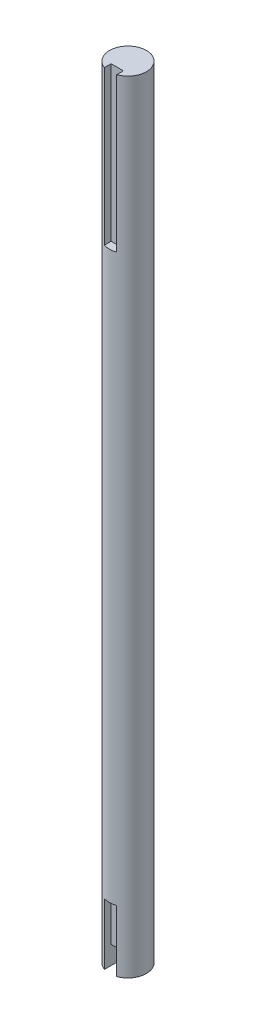
from build123d import *

# Parameters (mm, degrees)
SKETCH1_R               = 6
BOSS_EXTRUDE1_DEPTH     = 254
SKETCH2_W               = 4
SKETCH2_H               = 5
CUT_EXTRUDE3_DEPTH      = 20
CUT_EXTRUDE3_DEPTH_BACK = 0.0001
CUT_EXTRUDE4_START      = 254
SKETCH2_2_W             = 4
SKETCH2_2_H             = 5
CUT_EXTRUDE4_DEPTH      = 50
SKETCH3_W               = 4
SKETCH3_H               = 10
CUT_EXTRUDE6_DEPTH      = 6


with BuildPart() as part:
    # Sketch1 → Boss-Extrude1 (new body)
    with BuildSketch(Plane(origin=(0, 0, 0), x_dir=(1, 0, 0), z_dir=(0, 1, 0))):
        Circle(SKETCH1_R)
    extrude(amount=BOSS_EXTRUDE1_DEPTH)

    # Sketch2 → Cut-Extrude3 (cut, two sides)
    with BuildSketch(Plane(origin=(0, 0, 0), x_dir=(1, 0, 0), z_dir=(0, 1, 0))) as cut_extrude3_sk:
        with Locations((0, -6)):
            Rectangle(SKETCH2_W, SKETCH2_H)
    extrude(amount=CUT_EXTRUDE3_DEPTH, mode=Mode.SUBTRACT)
    extrude(cut_extrude3_sk.sketch, amount=-CUT_EXTRUDE3_DEPTH_BACK, mode=Mode.SUBTRACT)

    # Sketch2_2 → Cut-Extrude4 (cut)
    with BuildSketch(Plane(origin=(0, 0, 0), x_dir=(1, 0, 0), z_dir=(0, 1, 0)).offset(CUT_EXTRUDE4_START)):
        with Locations((0, -6)):
            Rectangle(SKETCH2_2_W, SKETCH2_2_H)
    extrude(amount=-CUT_EXTRUDE4_DEPTH, mode=Mode.SUBTRACT)

    # Sketch3 → Cut-Extrude6 (cut)
    with BuildSketch(Plane(origin=(0, 0, 0), x_dir=(1, 0, 0), z_dir=(0, 1, 0))):
        with Locations((0, -6)):
            Rectangle(SKETCH3_W, SKETCH3_H)
    extrude(amount=CUT_EXTRUDE6_DEPTH, mode=Mode.SUBTRACT)


solid = part.part
